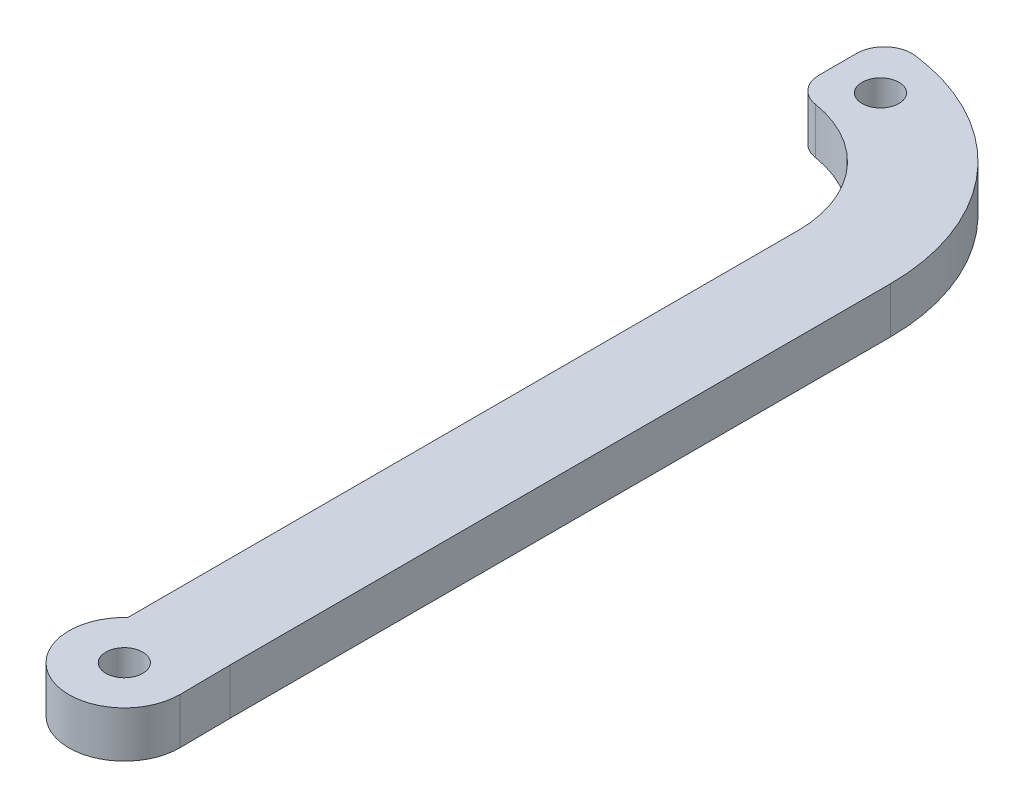
from build123d import *

# Parameters (mm, degrees)
SKETCH1_R           = 2
BOSS_EXTRUDE1_DEPTH = 5
FILLET1_R           = 3


with BuildPart() as part:
    # Sketch1 → Boss-Extrude1 (new body)
    with BuildSketch(Plane(origin=(0, 0, 0), x_dir=(1, 0, 0), z_dir=(0, 1, 0))):
        with BuildLine():
            Line((-4.055, 49.113152598), (-4.055, -16.120690269))
            Line((-4.055, -16.120690269), (-4.055, -23.51992753))
            ThreePointArc((-4.055, -23.51992753), (-2.3878384, -33.44590301), (5.99940006, -27.881853402))
            Line((5.99940006, -27.881853402), (5.945, -22.441847402))
            Line((5.945, -22.441847402), (5.945, 2.058152598))
            Line((5.945, 2.058152598), (5.945, 49.113152598))
            ThreePointArc((5.945, 49.113152598), (-0.775434906, 65.337717692), (-17, 72.058152598))
            Line((-17, 72.058152598), (-17.5, 72.058152598))
            Line((-17.5, 72.058152598), (-17.5, 62.058152598))
            Line((-17.5, 62.058152598), (-17, 62.058152598))
            ThreePointArc((-17, 62.058152598), (-7.846502718, 58.26664988), (-4.055, 49.113152598))
        make_face()
        with Locations((0, -27.941847402)):
            Circle(SKETCH1_R, mode=Mode.SUBTRACT)
        with Locations((-12.5, 66.491962252)):
            Circle(SKETCH1_R, mode=Mode.SUBTRACT)
    extrude(amount=BOSS_EXTRUDE1_DEPTH)

    # Fillet1
    fillet1_edges = [part.edges().sort_by_distance(p)[0] for p in [
        (-17.5, 2.5, -62.058152598),
        (-17.5, 2.5, -72.058152598),
    ]]
    fillet(fillet1_edges, radius=FILLET1_R)


solid = part.part
